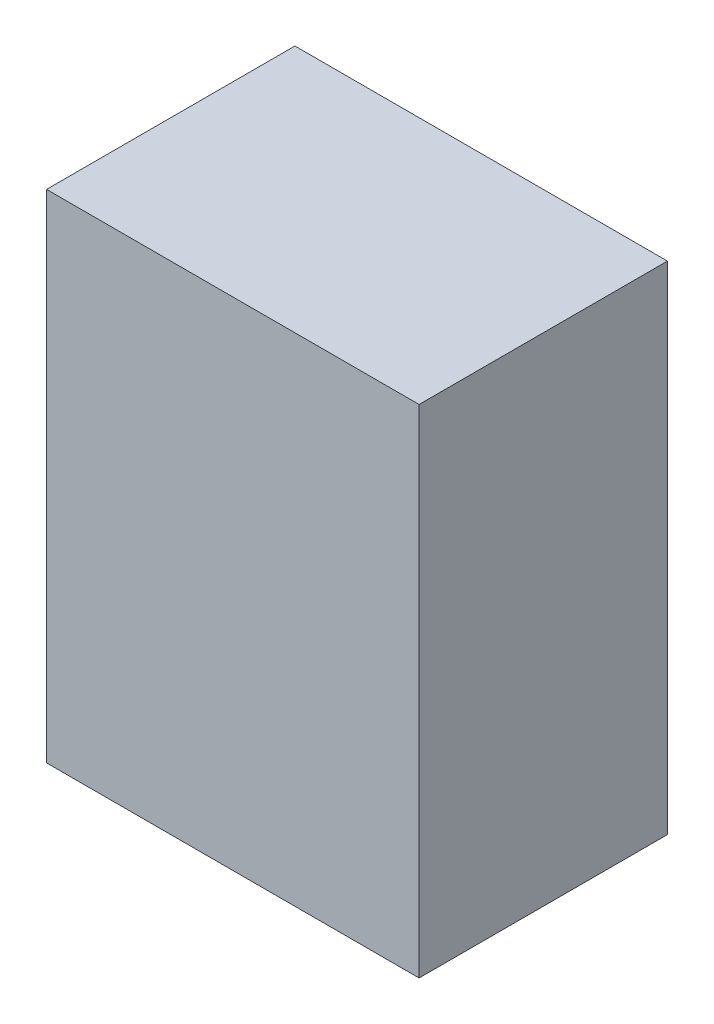
from build123d import *

# Parameters (mm, degrees)
SKETCH1_W           = 4.7625
SKETCH1_H           = 3.175
BOSS_EXTRUDE1_DEPTH = 6.35


with BuildPart() as part:
    # Sketch1 → Boss-Extrude1 (new body)
    with BuildSketch(Plane(origin=(0, 0, 0), x_dir=(1, 0, 0), z_dir=(0, 1, 0))):
        Rectangle(SKETCH1_W, SKETCH1_H)
    extrude(amount=BOSS_EXTRUDE1_DEPTH)


solid = part.part
